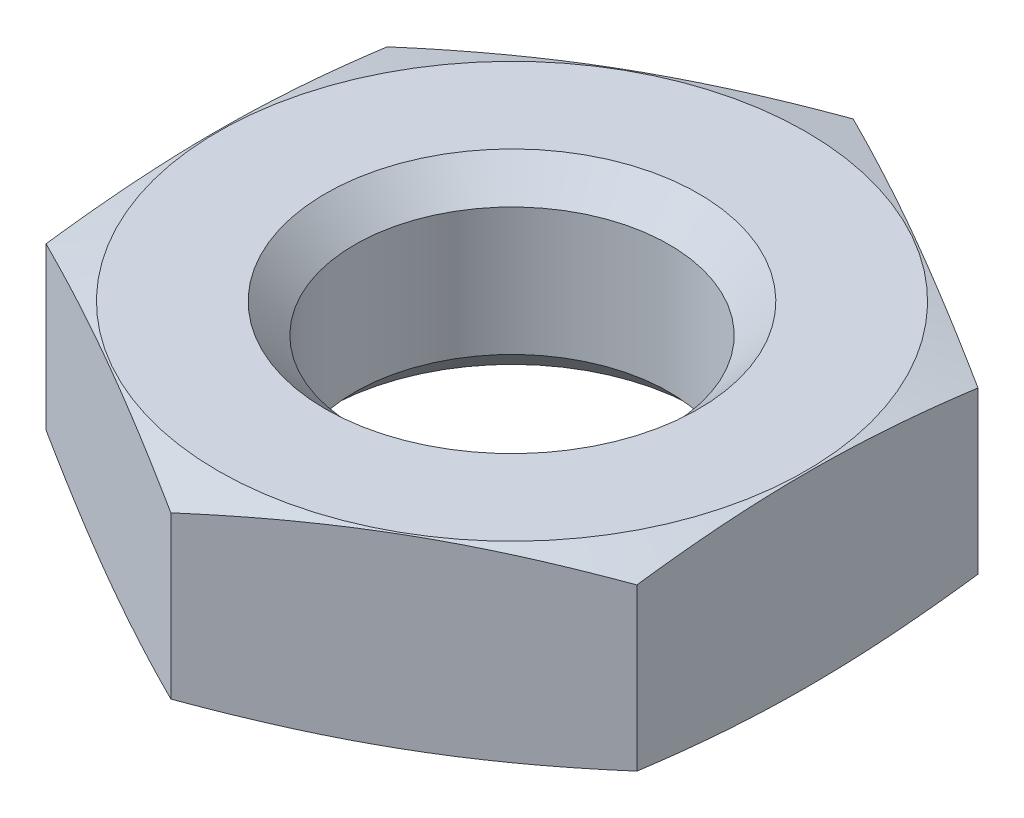
from build123d import *

# Parameters (mm, degrees)
CUT_EXTRUDE1_DEPTH      = 7
CUT_EXTRUDE1_DEPTH_BACK = 7
SKETCH2_W               = 76
SKETCH2_H               = 76


with BuildPart() as part:
    # Sketch1 → Revolve1 (revolve)
    with BuildSketch(Plane.XY):
        Polygon((0, 0), (9.45, 0), (20.646152423, -3), (9.45, -6), (0, -6), align=None)
    revolve(axis=Axis((0, -6, 0), (0, 1, 0)))

    # Sketch2 → Cut-Extrude1 (cut, two sides: drawn at the far end of the back side and taken through both)
    with BuildSketch(Plane(origin=(0, 0, 0), x_dir=(1, 0, 0), z_dir=(0, 1, 0)).offset(-CUT_EXTRUDE1_DEPTH_BACK)):
        Rectangle(SKETCH2_W, SKETCH2_H)
        Polygon((-9.5, -5.484827557), (0, -10.969655115), (9.5, -5.484827557), (9.5, 5.484827557), (0, 10.969655115), (-9.5, 5.484827557), align=None, mode=Mode.SUBTRACT)
    extrude(amount=CUT_EXTRUDE1_DEPTH + CUT_EXTRUDE1_DEPTH_BACK, mode=Mode.SUBTRACT)

    # Sketch3 → Cut-Revolve1 (revolve, cut)
    with BuildSketch(Plane.XY):
        Polygon((0, 0), (6, 0), (5.053, -0.947), (5.053, -5.053), (6, -6), (0, -6), align=None)
    revolve(axis=Axis((0, -6, 0), (0, 1, 0)), mode=Mode.SUBTRACT)


solid = part.part
